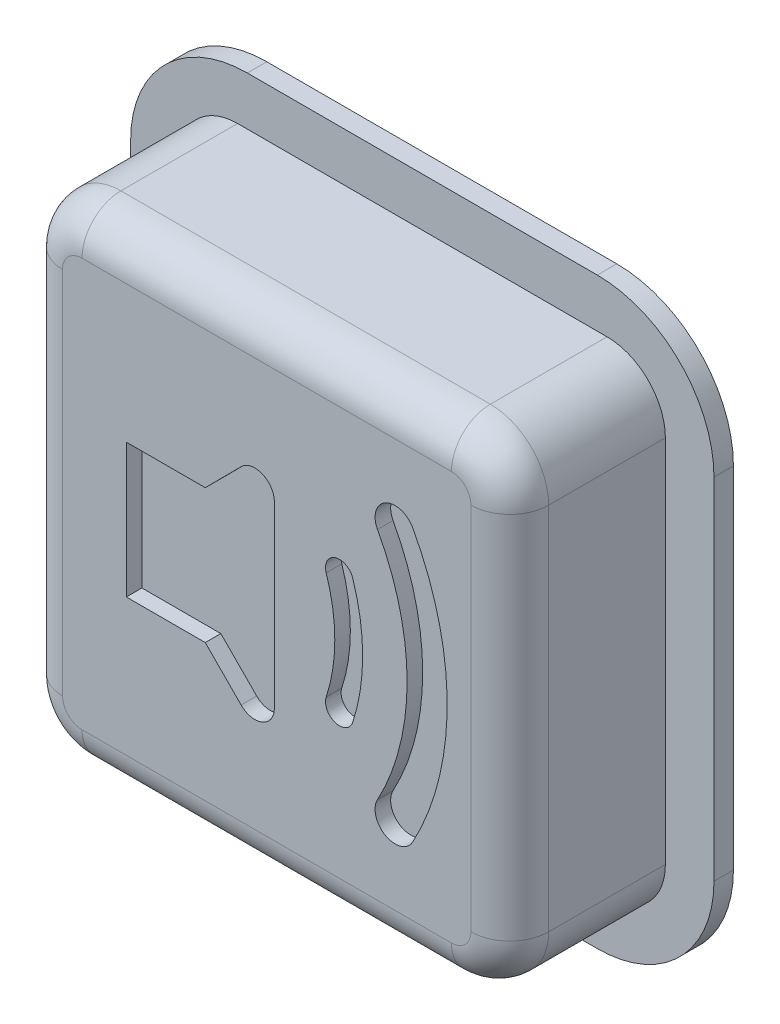
from build123d import *

# Parameters (mm, degrees)
SKETCH_1_W          = 12.5
SKETCH_1_H          = 12.5
EXTRUDE_412_DEPTH   = 4.5
FILLET_1_R          = 1.5
FILLET_2_R          = 1
SKETCH_2_W          = 15
SKETCH_2_H          = 15
EXTRUDE_1329_DEPTH  = 0.5
FILLET_3_R          = 3
CUT_EXTRUDE_1_DEPTH = 0.4
FILLET_4_R          = 0.5


with BuildPart() as part:
    # Эскиз1 → Extrude 412 (new body)
    with BuildSketch(Plane.XY):
        Rectangle(SKETCH_1_W, SKETCH_1_H)
    extrude(amount=EXTRUDE_412_DEPTH)

    # Скругление1
    fillet_1_edges = [part.edges().sort_by_distance(p)[0] for p in [
        (-6.25, 6.25, 2.25),
        (6.25, 6.25, 2.25),
        (6.25, -6.25, 2.25),
        (-6.25, -6.25, 2.25),
    ]]
    fillet(fillet_1_edges, radius=FILLET_1_R)

    # Скругление2
    fillet_2_edges = [part.edges().sort_by_distance(p)[0] for p in [
        (6.25, 0, 4.5),
        (0, -6.25, 4.5),
        (-6.25, 0, 4.5),
        (0, 6.25, 4.5),
        (-5.810660172, -5.810660172, 4.5),
        (-5.810660172, 5.810660172, 4.5),
        (5.810660172, 5.810660172, 4.5),
        (5.810660172, -5.810660172, 4.5),
    ]]
    fillet(fillet_2_edges, radius=FILLET_2_R)

    # Эскиз2 → Extrude 1329 (add)
    with BuildSketch(Plane(origin=(0, 0, 0), x_dir=(-1, 0, 0), z_dir=(0, 0, -1))):
        Rectangle(SKETCH_2_W, SKETCH_2_H)
    extrude(amount=-EXTRUDE_1329_DEPTH)

    # Скругление3
    fillet_3_edges = [part.edges().sort_by_distance(p)[0] for p in [
        (7.5, -7.5, 0.25),
        (7.5, 7.5, 0.25),
        (-7.5, 7.5, 0.25),
        (-7.5, -7.5, 0.25),
    ]]
    fillet(fillet_3_edges, radius=FILLET_3_R)

    # Эскиз4 → Вырез-Вытянуть1 (cut)
    with BuildSketch(Plane.XY.offset(4.5)):
        Polygon((-3.61015121, 1.724032908), (-3.61015121, -1.724032908), (-1.580654119, -1.724032908), (0.195408328, -3.515449311), (0.195408328, 3.515449311), (-1.580654119, 1.724032908), align=None)
        with BuildLine():
            ThreePointArc((1.529185986, -1.383686517), (1.749358373, 0), (1.529185986, 1.383686517))
            ThreePointArc((1.529185986, 1.383686517), (1.758587632, 1.835514539), (2.210415654, 1.606112893))
            ThreePointArc((2.210415654, 1.606112893), (2.465980556, 0), (2.210415654, -1.606112893))
            ThreePointArc((2.210415654, -1.606112893), (1.758587632, -1.835514539), (1.529185986, -1.383686517))
        make_face()
        with BuildLine():
            ThreePointArc((2.847646844, -3.007485014), (3.609370922, 0), (2.847646844, 3.007485014))
            ThreePointArc((2.847646844, 3.007485014), (3.055453428, 3.70569516), (3.753663574, 3.497888576))
            ThreePointArc((3.753663574, 3.497888576), (4.639595154, 0), (3.753663574, -3.497888576))
            ThreePointArc((3.753663574, -3.497888576), (3.055453428, -3.70569516), (2.847646844, -3.007485014))
        make_face()
    extrude(amount=-CUT_EXTRUDE_1_DEPTH, mode=Mode.SUBTRACT)

    # Скругление4
    fillet_4_edges = [part.edges().sort_by_distance(p)[0] for p in [
        (0.195408328, 3.515449311, 4.3),
        (0.195408328, -3.515449311, 4.3),
    ]]
    fillet(fillet_4_edges, radius=FILLET_4_R)


solid = part.part
